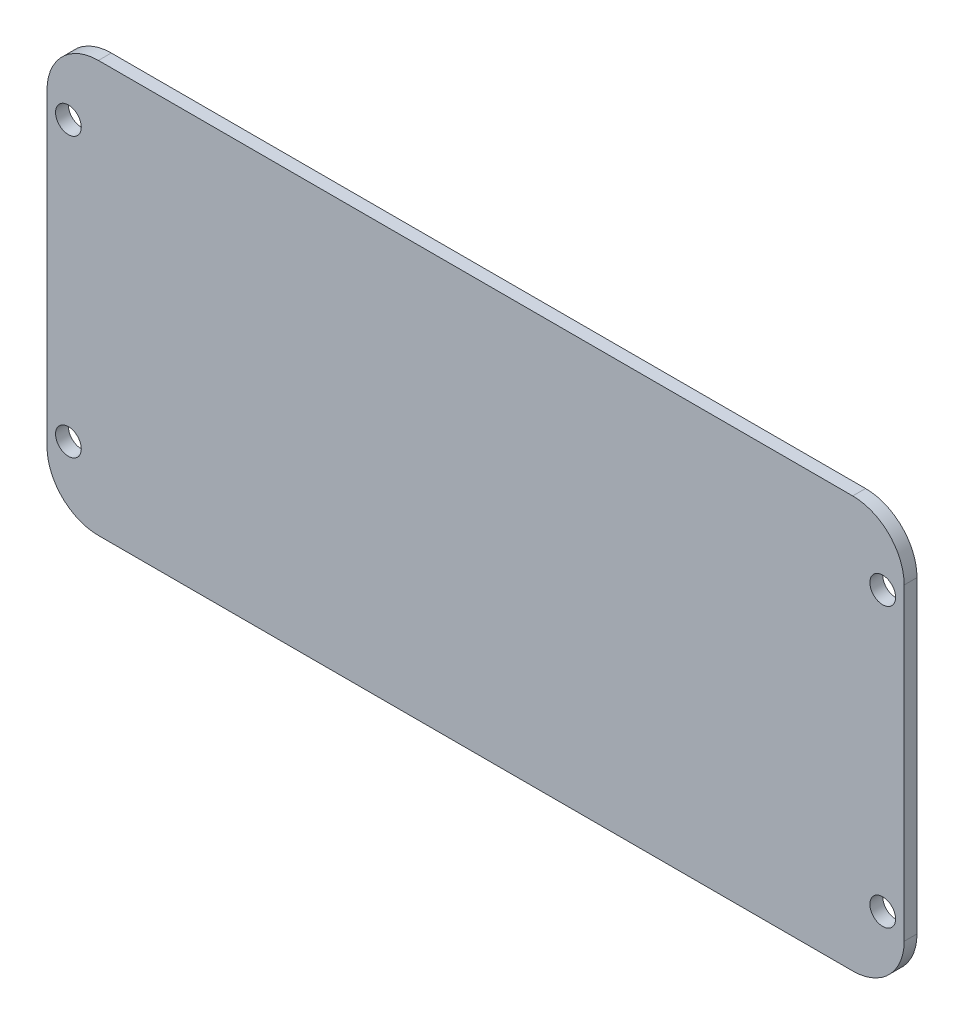
from build123d import *

# Parameters (mm, degrees)
CROQUIS1_R              = 1.5
SALIENTE_EXTRUIR1_DEPTH = 1.5


with BuildPart() as part:
    # Croquis1 → Saliente-Extruir1 (new body)
    with BuildSketch(Plane.XY):
        with BuildLine():
            Line((-38.589251844, 20.8), (49.410748156, 20.8))
            ThreePointArc((49.410748156, 20.8), (53.653388843, 19.042640687), (55.410748156, 14.8))
            Line((55.410748156, 14.8), (55.410748156, -21.2))
            ThreePointArc((55.410748156, -21.2), (53.653388843, -25.442640687), (49.410748156, -27.2))
            Line((49.410748156, -27.2), (-38.589251844, -27.2))
            ThreePointArc((-38.589251844, -27.2), (-42.831892531, -25.442640687), (-44.589251844, -21.2))
            Line((-44.589251844, -21.2), (-44.589251844, 14.8))
            ThreePointArc((-44.589251844, 14.8), (-42.831892531, 19.042640687), (-38.589251844, 20.8))
        make_face()
        with Locations((-42.089251844, 13.05)):
            Circle(CROQUIS1_R, mode=Mode.SUBTRACT)
        with Locations((-42.089251844, -19.45)):
            Circle(CROQUIS1_R, mode=Mode.SUBTRACT)
        with Locations((52.910748156, -19.45)):
            Circle(CROQUIS1_R, mode=Mode.SUBTRACT)
        with Locations((52.910748156, 13.05)):
            Circle(CROQUIS1_R, mode=Mode.SUBTRACT)
    extrude(amount=SALIENTE_EXTRUIR1_DEPTH)


solid = part.part
